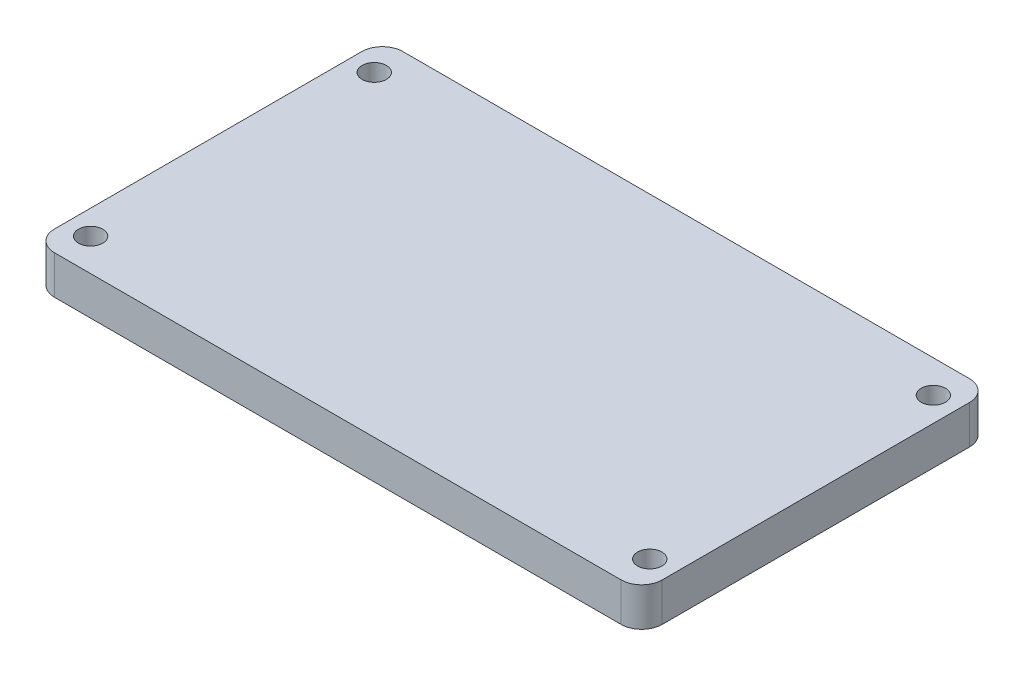
from build123d import *

# Parameters (mm, degrees)
SKETCH1_R           = 1.5
BOSS_EXTRUDE1_DEPTH = 4.7625


with BuildPart() as part:
    # Sketch1 → Boss-Extrude1 (new body)
    with BuildSketch(Plane(origin=(0, 0, 0), x_dir=(1, 0, 0), z_dir=(0, 1, 0))):
        with BuildLine():
            Line((-34.96, -21.5), (34.96, -21.5))
            ThreePointArc((34.96, -21.5), (36.756051224, -20.756051224), (37.5, -18.96))
            Line((37.5, -18.96), (37.5, 18.96))
            ThreePointArc((37.5, 18.96), (36.756051224, 20.756051224), (34.96, 21.5))
            Line((34.96, 21.5), (-34.96, 21.5))
            ThreePointArc((-34.96, 21.5), (-36.756051224, 20.756051224), (-37.5, 18.96))
            Line((-37.5, 18.96), (-37.5, -18.96))
            ThreePointArc((-37.5, -18.96), (-36.756051224, -20.756051224), (-34.96, -21.5))
        make_face()
        with Locations((-34.5, 17.5)):
            Circle(SKETCH1_R, mode=Mode.SUBTRACT)
        with Locations((-34.5, -17.5)):
            Circle(SKETCH1_R, mode=Mode.SUBTRACT)
        with Locations((34.5, -17.5)):
            Circle(SKETCH1_R, mode=Mode.SUBTRACT)
        with Locations((34.5, 17.5)):
            Circle(SKETCH1_R, mode=Mode.SUBTRACT)
    extrude(amount=BOSS_EXTRUDE1_DEPTH)


solid = part.part
